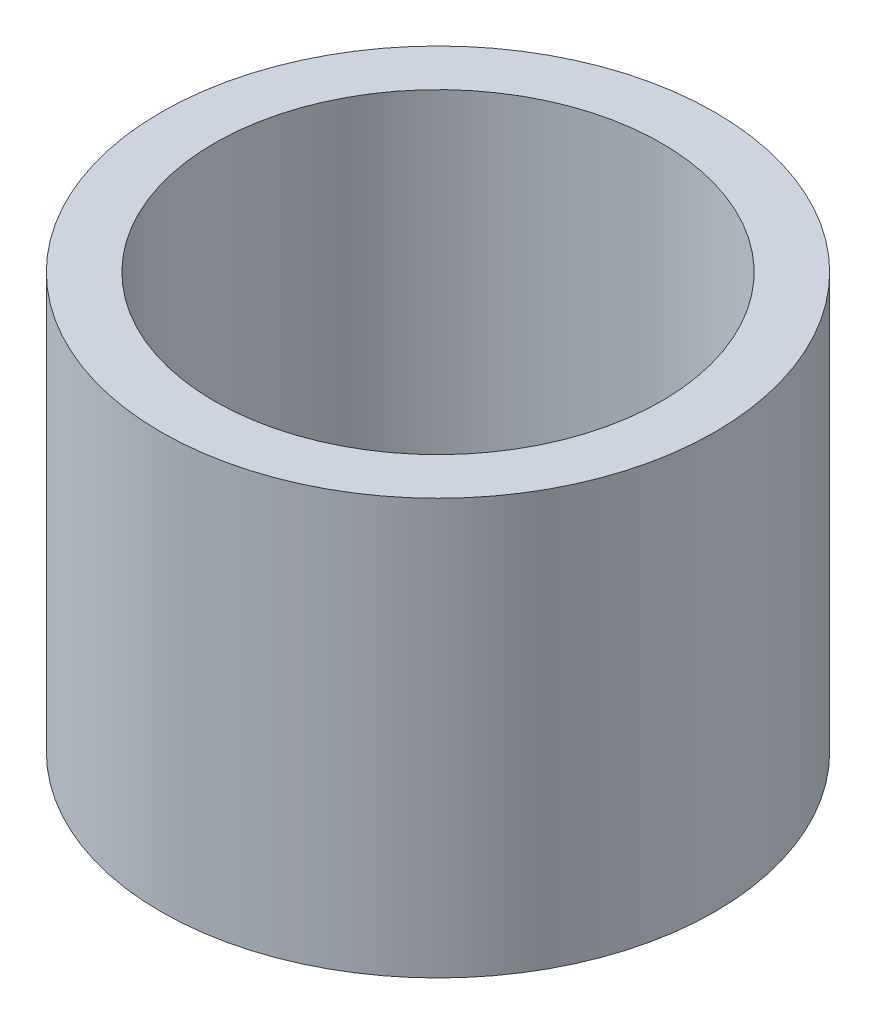
from build123d import *

# Parameters (mm, degrees)
SKETCH_1_W = 4.9
SKETCH_1_H = 38.1


with BuildPart() as part:
    # 草图1 → 旋转1 (revolve)
    with BuildSketch(Plane.XY, mode=Mode.PRIVATE) as revolve_1_sk:
        with Locations((22.95, 19.05)):
            Rectangle(SKETCH_1_W, SKETCH_1_H)
    revolve(revolve_1_sk.sketch.rotate(Axis((0, 161.376166943, 0), (0, -1, 0)), 90), axis=Axis((0, 161.376166943, 0), (0, -1, 0)))  # turned: the seam where the file's is


solid = part.part
